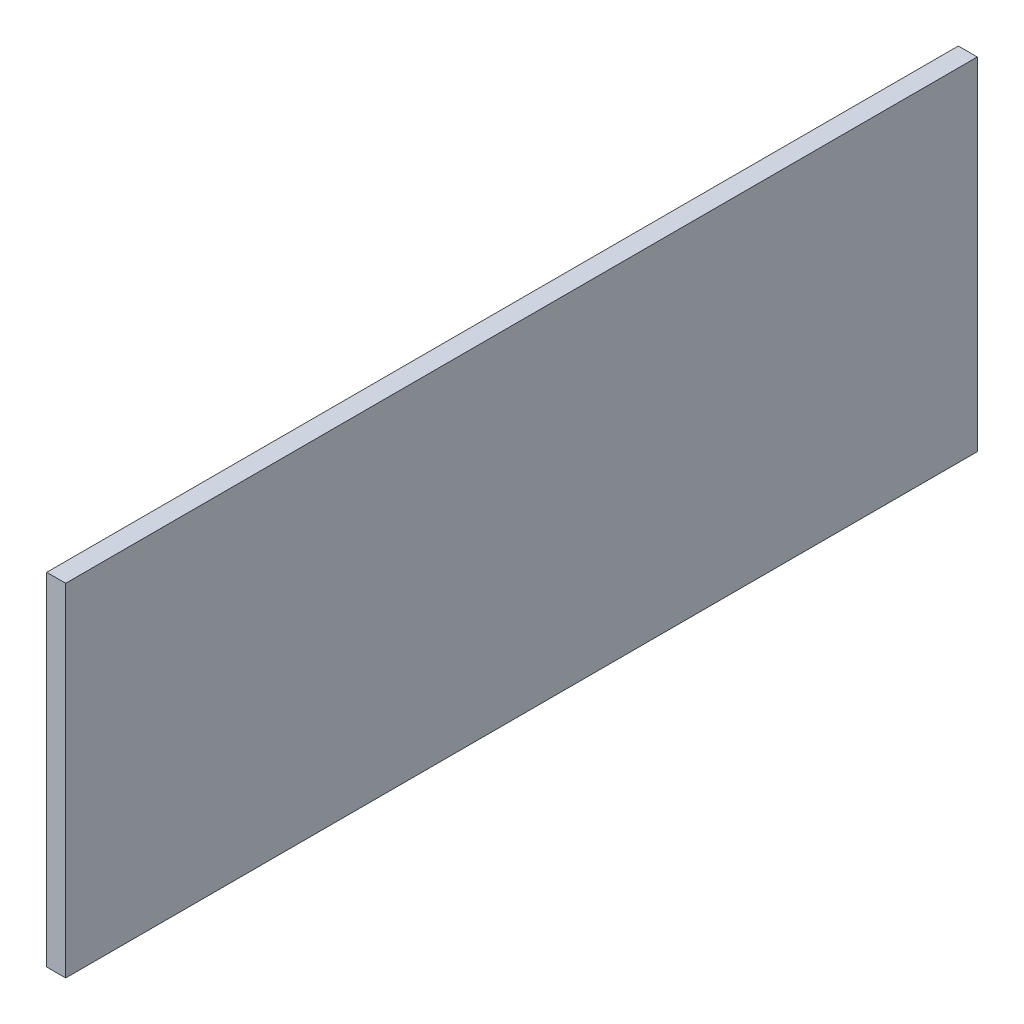
from build123d import *

# Parameters (mm, degrees)
SKETCH1_W           = 14630.4
SKETCH1_H           = 5486.4
BOSS_EXTRUDE1_DEPTH = 304.8


with BuildPart() as part:
    # Sketch1 → Boss-Extrude1 (new body)
    with BuildSketch(Plane(origin=(0, 0, 0), x_dir=(0, 0, -1), z_dir=(1, 0, 0))):
        with Locations((-7315.2, -2743.2)):
            Rectangle(SKETCH1_W, SKETCH1_H)
    extrude(amount=BOSS_EXTRUDE1_DEPTH)


solid = part.part
